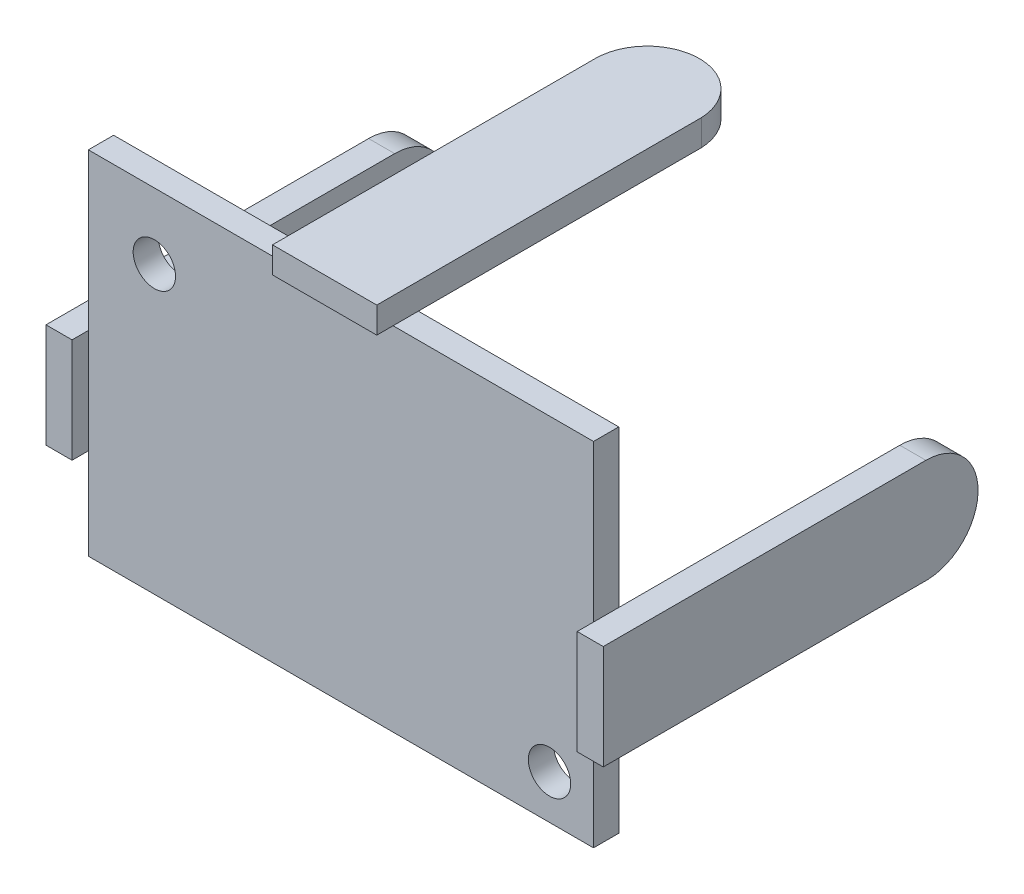
from build123d import *

# Parameters (mm, degrees)
SKETCH1_W           = 31
SKETCH1_H           = 21.6
SKETCH1_R           = 1.3
BOSS_EXTRUDE1_DEPTH = 1.55
BOSS_EXTRUDE2_START = 15.5
BOSS_EXTRUDE2_DEPTH = 1.6
BOSS_EXTRUDE3_START = -15.5
BOSS_EXTRUDE3_DEPTH = 1.6
BOSS_EXTRUDE4_DEPTH = 1.6


with BuildPart() as part:
    # Sketch1 → Boss-Extrude1 (new body)
    with BuildSketch(Plane.XY):
        Rectangle(SKETCH1_W, SKETCH1_H)
        with Locations((12.8, -8.1)):
            Circle(SKETCH1_R, mode=Mode.SUBTRACT)
        with Locations((-11.45, 6.75)):
            Circle(SKETCH1_R, mode=Mode.SUBTRACT)
    extrude(amount=BOSS_EXTRUDE1_DEPTH)

    # Sketch2_2 → Boss-Extrude3 (add)
    with BuildSketch(Plane(origin=(0, 0, 0), x_dir=(0, 0, -1), z_dir=(1, 0, 0)).offset(BOSS_EXTRUDE3_START)):
        with BuildLine():
            Line((-2.55, 1.2), (17.248963494, 1.2))
            ThreePointArc((17.248963494, 1.2), (20.449481705, -1.943435359), (17.364147134, -5.2))
            Line((17.364147134, -5.2), (-2.55, -5.2))
            Line((-2.55, -5.2), (-2.55, 1.2))
        make_face()
    extrude(amount=-BOSS_EXTRUDE3_DEPTH)

    # Sketch3 → Boss-Extrude4 (add)
    with BuildSketch(Plane(origin=(0, 10.8, 0), x_dir=(1, 0, 0), z_dir=(0, 1, 0))):
        with BuildLine():
            Line((-3.2, -2.55), (-3.2, 17.248963494))
            ThreePointArc((-3.2, 17.248963494), (-0.056564641, 20.449481705), (3.2, 17.364147134))
            Line((3.2, 17.364147134), (3.2, -2.55))
            Line((3.2, -2.55), (-3.2, -2.55))
        make_face()
    extrude(amount=BOSS_EXTRUDE4_DEPTH)


with BuildPart() as body_2:
    # Sketch2 → Boss-Extrude2 (new body)
    with BuildSketch(Plane(origin=(0, 0, 0), x_dir=(0, 0, -1), z_dir=(1, 0, 0)).offset(BOSS_EXTRUDE2_START)):
        with BuildLine():
            Line((-2.55, 1.2), (17.248963494, 1.2))
            ThreePointArc((17.248963494, 1.2), (20.449481705, -1.943435359), (17.364147134, -5.2))
            Line((17.364147134, -5.2), (-2.55, -5.2))
            Line((-2.55, -5.2), (-2.55, 1.2))
        make_face()
    extrude(amount=BOSS_EXTRUDE2_DEPTH)


solid = Compound([part.part, body_2.part])
